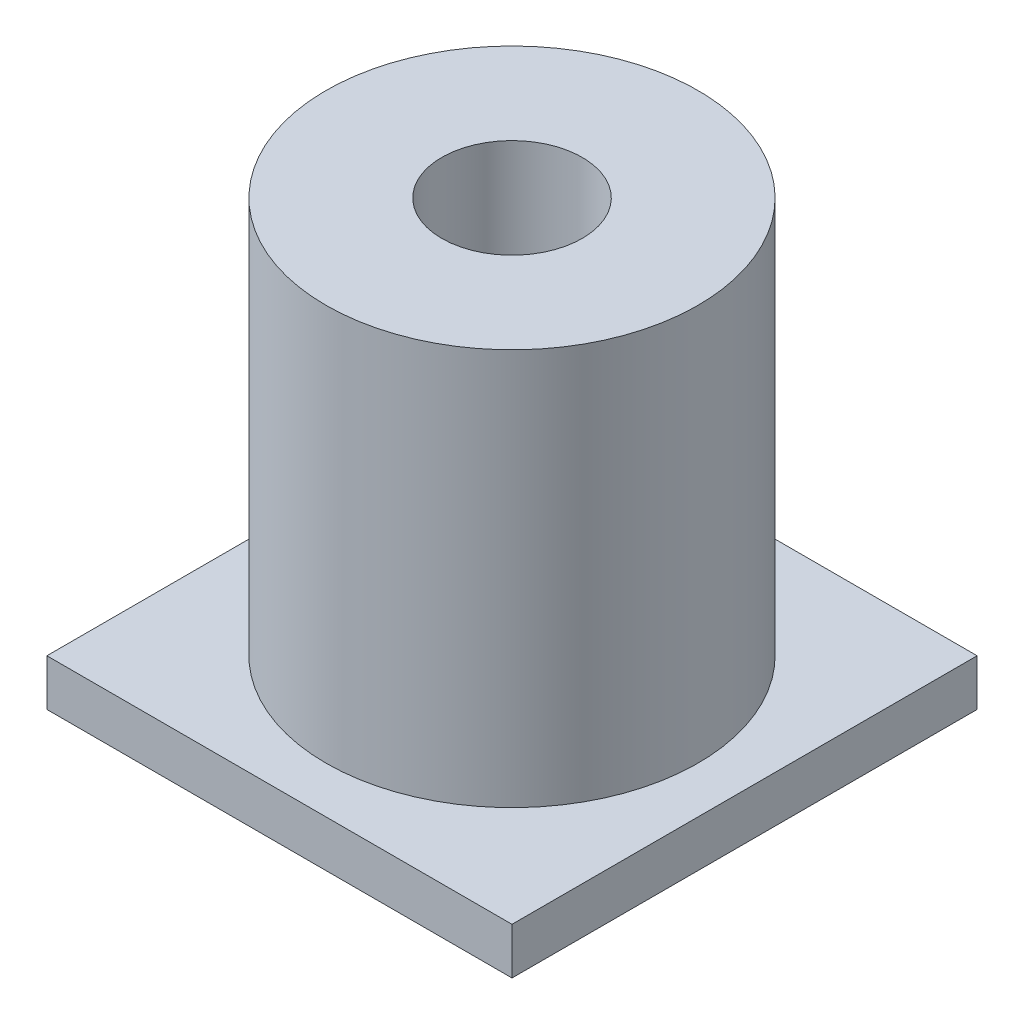
from build123d import *

# Parameters (mm, degrees)
SKETCH1_W           = 10
SKETCH1_H           = 10
SKETCH1_R           = 1.25
BOSS_EXTRUDE1_DEPTH = 1
SKETCH2_R           = 4
SKETCH2_R_2         = 1.51
BOSS_EXTRUDE2_DEPTH = 8.525


with BuildPart() as part:
    # Sketch1 → Boss-Extrude1 (new body)
    with BuildSketch(Plane(origin=(0, 0, 0), x_dir=(1, 0, 0), z_dir=(0, 1, 0))):
        with Locations((5, -5)):
            Rectangle(SKETCH1_W, SKETCH1_H)
        with Locations((5, -5)):
            Circle(SKETCH1_R, mode=Mode.SUBTRACT)
    extrude(amount=BOSS_EXTRUDE1_DEPTH)

    # Sketch2 → Boss-Extrude2 (add)
    with BuildSketch(Plane(origin=(0, 1, 0), x_dir=(1, 0, 0), z_dir=(0, 1, 0))):
        with Locations((5, -5)):
            Circle(SKETCH2_R)
        with Locations((5, -5)):
            Circle(SKETCH2_R_2, mode=Mode.SUBTRACT)
    extrude(amount=BOSS_EXTRUDE2_DEPTH)


solid = part.part
